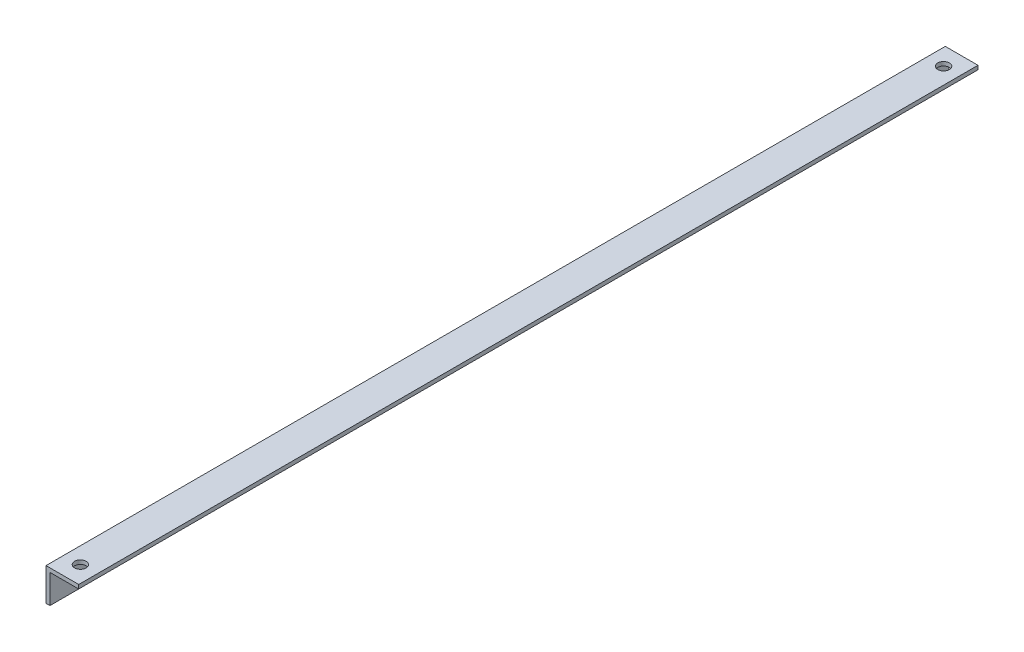
from build123d import *

# Parameters (mm, degrees)
BOSS_EXTRUDE1_DEPTH   = 349
M4_CLEARANCE_HOLE1_D  = 4.5
M4X0_7_TAPPED_HOLE1_D = 3.3


with BuildPart() as part:
    # Sketch1 → Boss-Extrude1 (new body)
    with BuildSketch(Plane.XY):
        Polygon((0, 0), (12.7, 0), (12.7, -1.524), (1.524, -1.524), (1.524, -12.7), (0, -12.7), align=None)
    extrude(amount=BOSS_EXTRUDE1_DEPTH)

    # M4 Clearance Hole1 (through all)
    with Locations(Plane(origin=(0, 0, 0), x_dir=(1, 0, 0), z_dir=(0, 1, 0))):
        with Locations((6.35, -7), (6.35, -342)):
            Hole(M4_CLEARANCE_HOLE1_D / 2)

    # M4x0.7 Tapped Hole1 (through all)
    with Locations(Plane.ZY):
        with Locations((65.553973, -6.35), (283.446027, -6.35)):
            Hole(M4X0_7_TAPPED_HOLE1_D / 2)


solid = part.part
